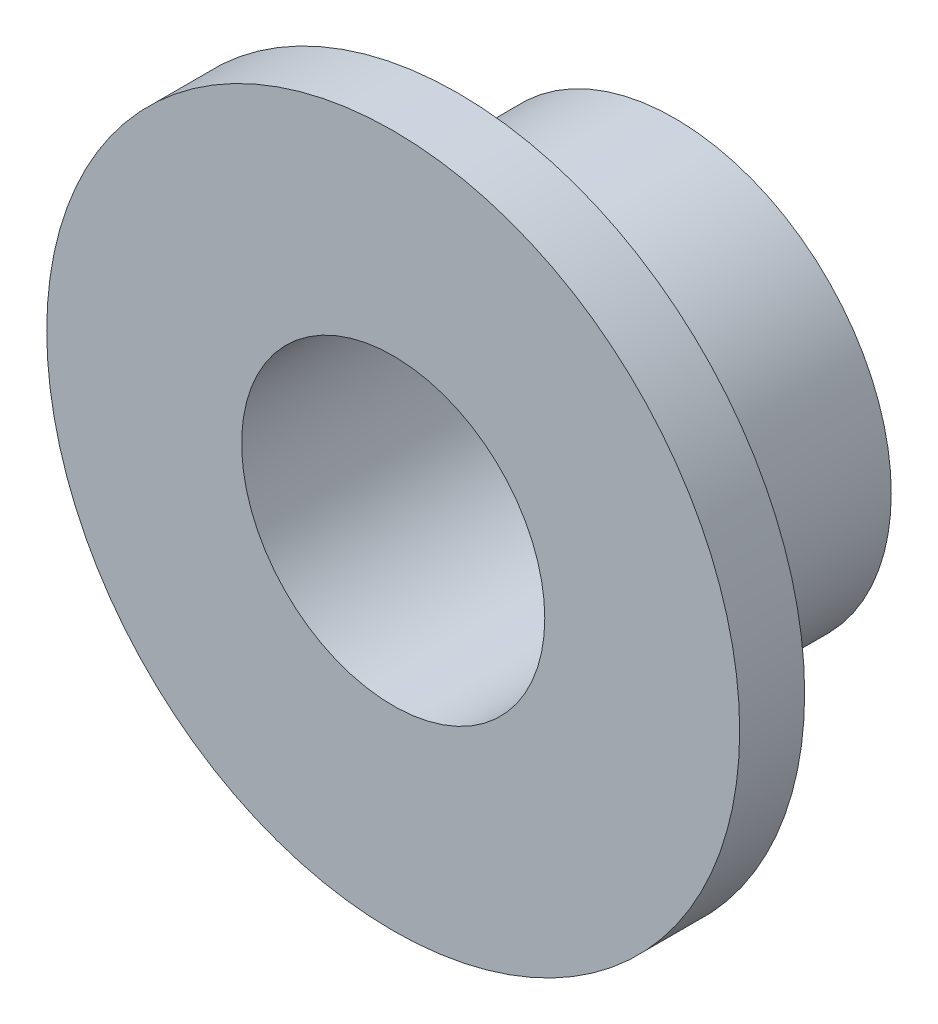
from build123d import *

# Parameters (mm, degrees)
SKETCH1_R           = 10
SKETCH1_R_2         = 7
BOSS_EXTRUDE1_DEPTH = 10
SKETCH2_R           = 16
SKETCH2_R_2         = 10
SKETCH2_R_3         = 7
BOSS_EXTRUDE3_DEPTH = 3


with BuildPart() as part:
    # Sketch1 → Boss-Extrude1 (new body)
    with BuildSketch(Plane.XY):
        Circle(SKETCH1_R)
        Circle(SKETCH1_R_2, mode=Mode.SUBTRACT)
    extrude(amount=BOSS_EXTRUDE1_DEPTH)

    # Sketch2 → Boss-Extrude3 (add)
    with BuildSketch(Plane.XY.offset(10)):
        Circle(SKETCH2_R)
        Circle(SKETCH2_R_2, mode=Mode.SUBTRACT)
        Circle(SKETCH2_R_2)
        Circle(SKETCH2_R_3, mode=Mode.SUBTRACT)
    extrude(amount=BOSS_EXTRUDE3_DEPTH)


solid = part.part
